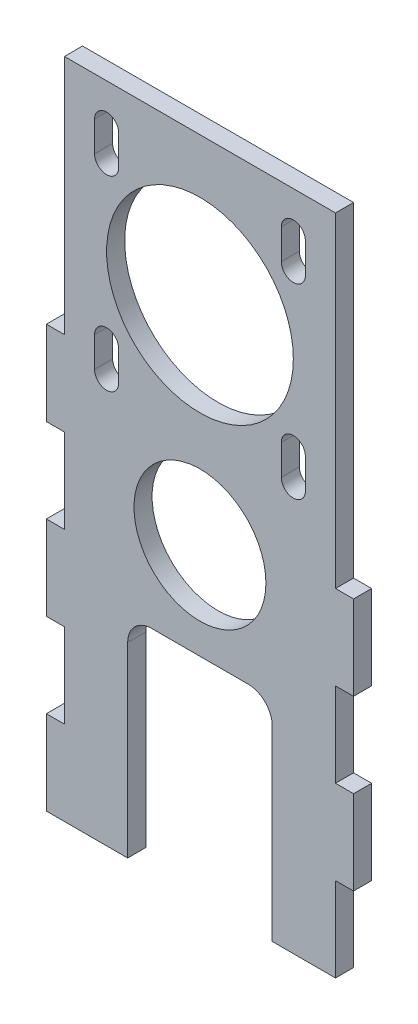
from build123d import *

# Parameters (mm, degrees)
SKETCH1_W           = 45
SKETCH1_H           = 110
BOSS_EXTRUDE1_DEPTH = 3
SKETCH2_R           = 10.95
SKETCH2_R_2         = 15.5
SKETCH2_W           = 24
SKETCH2_H           = 35
CUT_EXTRUDE1_DEPTH  = 4
FILLET1_R           = 4
SKETCH3_W           = 3
SKETCH3_H           = 14
BOSS_EXTRUDE2_DEPTH = 3


with BuildPart() as part:
    # Sketch1 → Boss-Extrude1 (new body)
    with BuildSketch(Plane.XY):
        Rectangle(SKETCH1_W, SKETCH1_H)
    extrude(amount=BOSS_EXTRUDE1_DEPTH)

    # Sketch2 → Cut-Extrude1 (cut, through all)
    with BuildSketch(Plane.XY.offset(3)):
        with Locations((0, -4)):
            Circle(SKETCH2_R)
        with Locations((0, 30.5)):
            Circle(SKETCH2_R_2)
        with Locations((0, -37.5)):
            Rectangle(SKETCH2_W, SKETCH2_H)
        with BuildLine():
            Line((-17.5, 43.5), (-17.5, 48.5))
            ThreePointArc((-17.5, 48.5), (-15.5, 50.5), (-13.5, 48.5))
            Line((-13.5, 48.5), (-13.5, 43.5))
            ThreePointArc((-13.5, 43.5), (-15.5, 41.5), (-17.5, 43.5))
        make_face()
        with BuildLine():
            Line((-13.5, 17.5), (-13.5, 12.5))
            ThreePointArc((-13.5, 12.5), (-15.5, 10.5), (-17.5, 12.5))
            Line((-17.5, 12.5), (-17.5, 17.5))
            ThreePointArc((-17.5, 17.5), (-15.5, 19.5), (-13.5, 17.5))
        make_face()
        with BuildLine():
            Line((17.5, 17.5), (17.5, 12.5))
            ThreePointArc((17.5, 12.5), (15.5, 10.5), (13.5, 12.5))
            Line((13.5, 12.5), (13.5, 17.5))
            ThreePointArc((13.5, 17.5), (15.5, 19.5), (17.5, 17.5))
        make_face()
        with BuildLine():
            Line((13.5, 43.5), (13.5, 48.5))
            ThreePointArc((13.5, 48.5), (15.5, 50.5), (17.5, 48.5))
            Line((17.5, 48.5), (17.5, 43.5))
            ThreePointArc((17.5, 43.5), (15.5, 41.5), (13.5, 43.5))
        make_face()
    extrude(amount=-CUT_EXTRUDE1_DEPTH, mode=Mode.SUBTRACT)

    # Fillet1
    fillet1_edges = [part.edges().sort_by_distance(p)[0] for p in [
        (12, -20, 1.5),
        (-12, -20, 1.5),
    ]]
    fillet(fillet1_edges, radius=FILLET1_R)

    # Sketch3 → Boss-Extrude2 (add)
    with BuildSketch(Plane.XY.offset(3)):
        with Locations((-24, -20)):
            Rectangle(SKETCH3_W, SKETCH3_H)
        with Locations((-24, 8)):
            Rectangle(SKETCH3_W, SKETCH3_H)
        with Locations((-24, -48)):
            Rectangle(SKETCH3_W, SKETCH3_H)
        with Locations((24, -6)):
            Rectangle(SKETCH3_W, SKETCH3_H)
        with Locations((24, -34)):
            Rectangle(SKETCH3_W, SKETCH3_H)
    extrude(amount=-BOSS_EXTRUDE2_DEPTH)


solid = part.part
